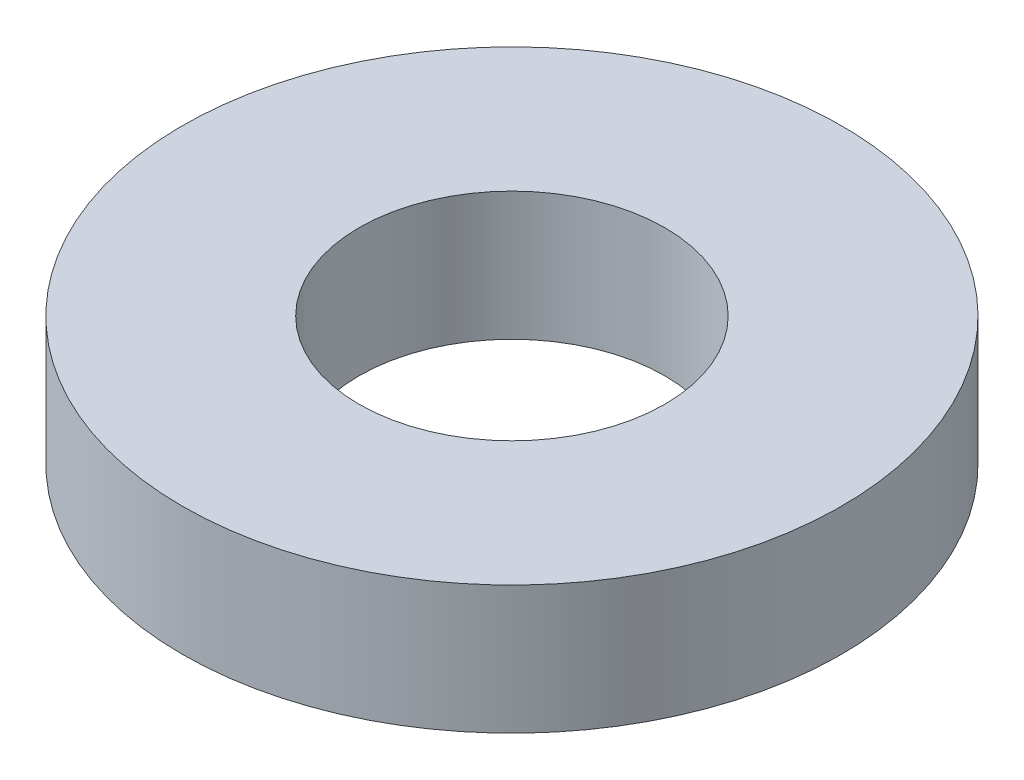
from build123d import *

# Parameters (mm, degrees)
SKETCH1_R           = 4.7625
BOSS_EXTRUDE1_DEPTH = 1.8542
SKETCH5_R           = 2.2098
CUT_EXTRUDE1_DEPTH  = 2.8542


with BuildPart() as part:
    # Sketch1 → Boss-Extrude1 (new body)
    with BuildSketch(Plane(origin=(0, 0, 0), x_dir=(1, 0, 0), z_dir=(0, 1, 0))):
        Circle(SKETCH1_R)
    extrude(amount=BOSS_EXTRUDE1_DEPTH)

    # Sketch5 → Cut-Extrude1 (cut, through all)
    with BuildSketch(Plane(origin=(0, 1.8542, 0), x_dir=(-1, 0, 0), z_dir=(0, 1, 0))):
        Circle(SKETCH5_R)
    extrude(amount=-CUT_EXTRUDE1_DEPTH, mode=Mode.SUBTRACT)


solid = part.part
